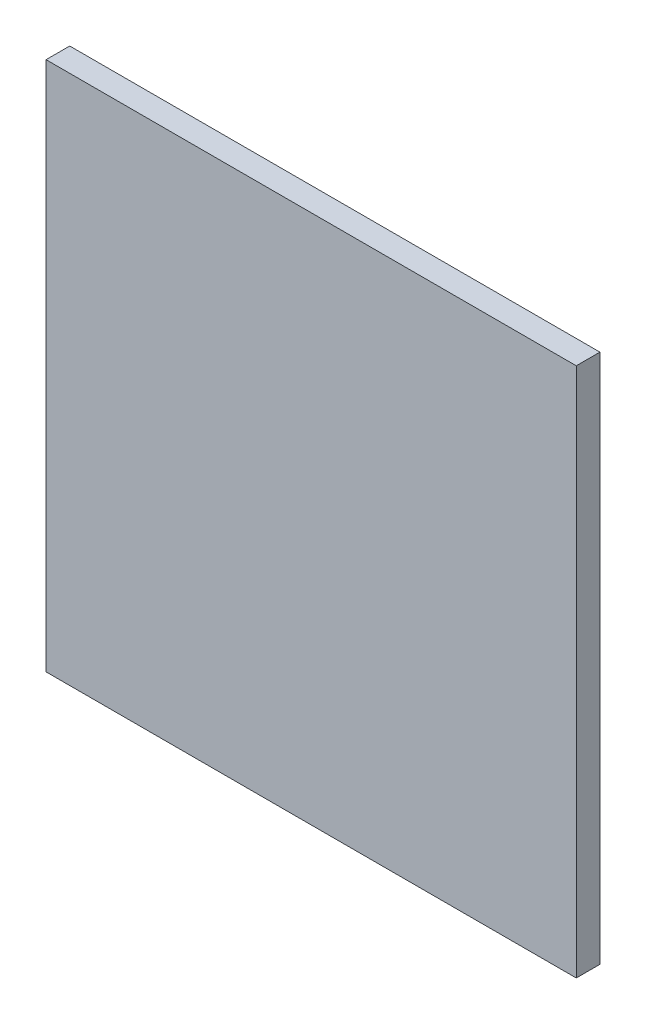
from build123d import *

# Parameters (mm, degrees)
SKETCH1_W           = 71.12
SKETCH1_H           = 71.12
BOSS_EXTRUDE1_DEPTH = 3.175


with BuildPart() as part:
    # Sketch1 → Boss-Extrude1 (new body)
    with BuildSketch(Plane.XY):
        with Locations((-50.83409396, 7.517718121)):
            Rectangle(SKETCH1_W, SKETCH1_H)
    extrude(amount=BOSS_EXTRUDE1_DEPTH)


solid = part.part
